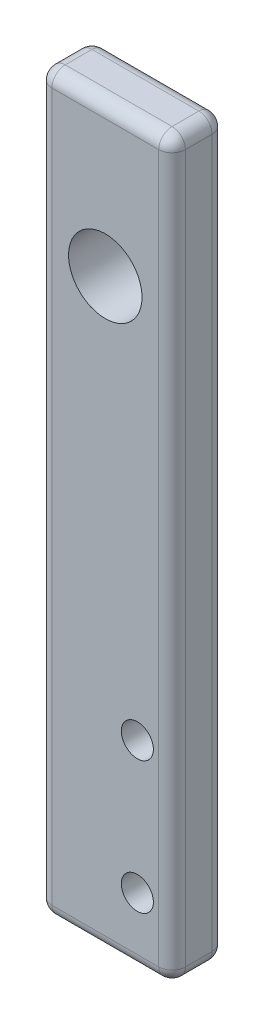
from build123d import *

# Parameters (mm, degrees)
SKETCH1_W           = 10
SKETCH1_H           = 55
SKETCH1_R           = 1.2
SKETCH1_R_2         = 2.75
BOSS_EXTRUDE1_DEPTH = 4
FILLET1_R           = 1


with BuildPart() as part:
    # Sketch1 → Boss-Extrude1 (new body)
    with BuildSketch(Plane.XY):
        with Locations((5, 27.5)):
            Rectangle(SKETCH1_W, SKETCH1_H)
        with Locations((7.4, 5)):
            Circle(SKETCH1_R, mode=Mode.SUBTRACT)
        with Locations((7.4, 14.9)):
            Circle(SKETCH1_R, mode=Mode.SUBTRACT)
        with Locations((5, 43.792878619)):
            Circle(SKETCH1_R_2, mode=Mode.SUBTRACT)
    extrude(amount=BOSS_EXTRUDE1_DEPTH)

    # Fillet1
    fillet1_edges = [part.edges().sort_by_distance(p)[0] for p in [
        (10, 27.5, 4),
        (5, 55, 4),
        (0, 27.5, 4),
        (5, 55, 0),
        (10, 27.5, 0),
        (5, 0, 0),
        (0, 27.5, 0),
        (0, 55, 2),
        (10, 55, 2),
        (10, 0, 2),
        (0, 0, 2),
        (5, 0, 4),
    ]]
    fillet(fillet1_edges, radius=FILLET1_R)


solid = part.part
